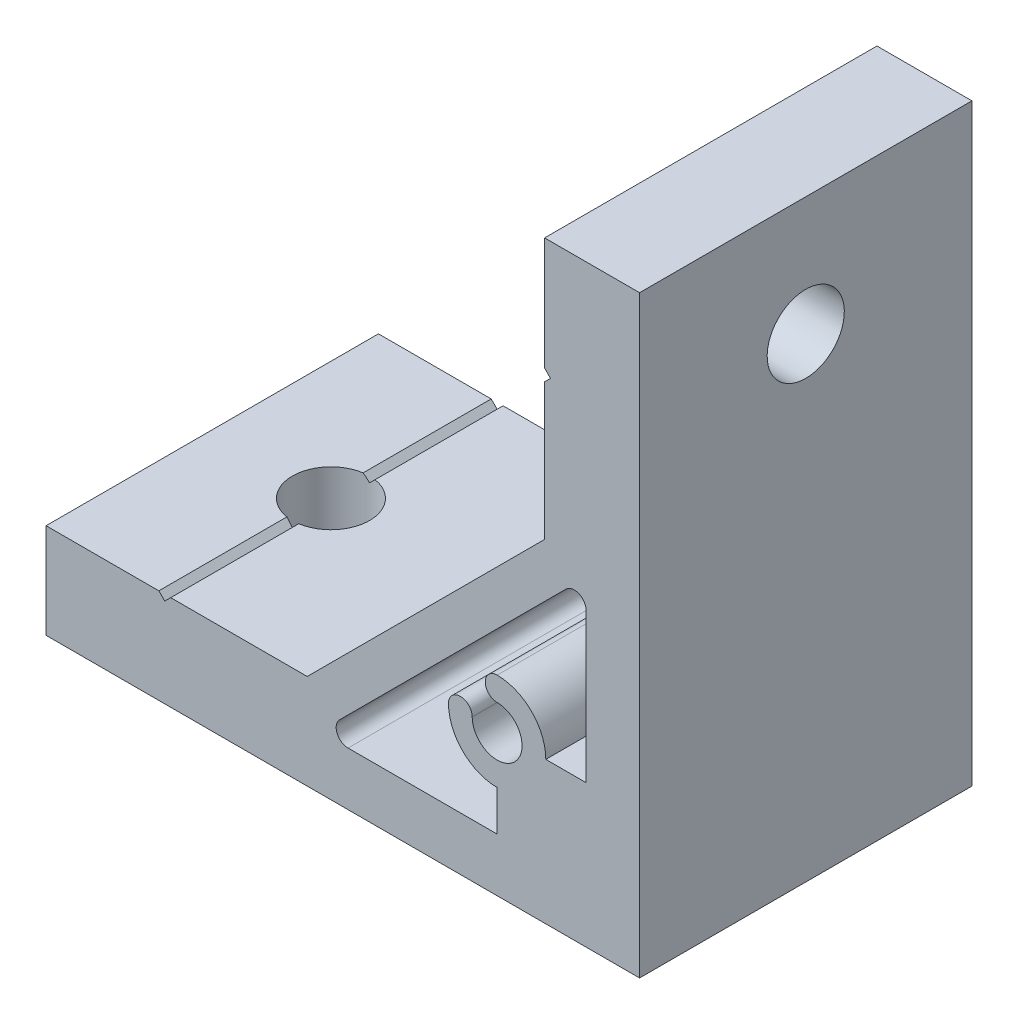
from build123d import *

# Parameters (mm, degrees)
EXTRUDE_1_DEPTH     = 14
SKETCH_2_R          = 3.25
CUT_EXTRUDE_1_DEPTH = 9
SKETCH_3_R          = 3.25
CUT_EXTRUDE_2_DEPTH = 9


with BuildPart() as part:
    # Эскиз1 → Бобышка-Вытянуть1 (new body, symmetric)
    with BuildSketch(Plane.XY):
        Polygon((-50, 0), (0, 0), (0, 50), (-8, 50), (-8, 40.5), (-7.5, 40), (-8, 39.5), (-8, 28), (-28, 8), (-39.5, 8), (-40, 7.5), (-40.5, 8), (-50, 8), align=None)
        with BuildLine():
            Line((-4.5, 12), (-4.5, 24.560303038))
            ThreePointArc((-4.5, 24.560303038), (-5.117316568, 25.484182571), (-6.207106781, 25.267409819))
            Line((-6.207106781, 25.267409819), (-25.267409819, 6.207106781))
            ThreePointArc((-25.267409819, 6.207106781), (-25.484182571, 5.117316568), (-24.560303038, 4.5))
            Line((-24.560303038, 4.5), (-12, 4.5))
            Line((-12, 4.5), (-12, 7.9))
            ThreePointArc((-12, 7.9), (-14.899137803, 9.100862197), (-16.1, 12))
            ThreePointArc((-16.1, 12), (-15.1, 13), (-14.1, 12))
            ThreePointArc((-14.1, 12), (-10.51507576, 10.51507576), (-12, 14.1))
            ThreePointArc((-12, 14.1), (-13, 15.1), (-12, 16.1))
            ThreePointArc((-12, 16.1), (-9.100862197, 14.899137803), (-7.9, 12))
            Line((-7.9, 12), (-4.5, 12))
        make_face(mode=Mode.SUBTRACT)
    extrude(amount=EXTRUDE_1_DEPTH, both=True)

    # Эскиз2 → Вырез-Вытянуть1 (cut, through all)
    with BuildSketch(Plane.ZY.offset(8)):
        with Locations(Location((0, 40, 0), (0, 0, 270))):  # turned: the seam where the file's is
            Circle(SKETCH_2_R)
    extrude(amount=-CUT_EXTRUDE_1_DEPTH, mode=Mode.SUBTRACT)

    # Эскиз3 → Вырез-Вытянуть2 (cut, through all)
    with BuildSketch(Plane(origin=(0, 8, 0), x_dir=(1, 0, 0), z_dir=(0, 1, 0))):
        with Locations(Location((-40, 0, 0), (0, 0, 180))):  # turned: the seam where the file's is
            Circle(SKETCH_3_R)
    extrude(amount=-CUT_EXTRUDE_2_DEPTH, mode=Mode.SUBTRACT)


solid = part.part
